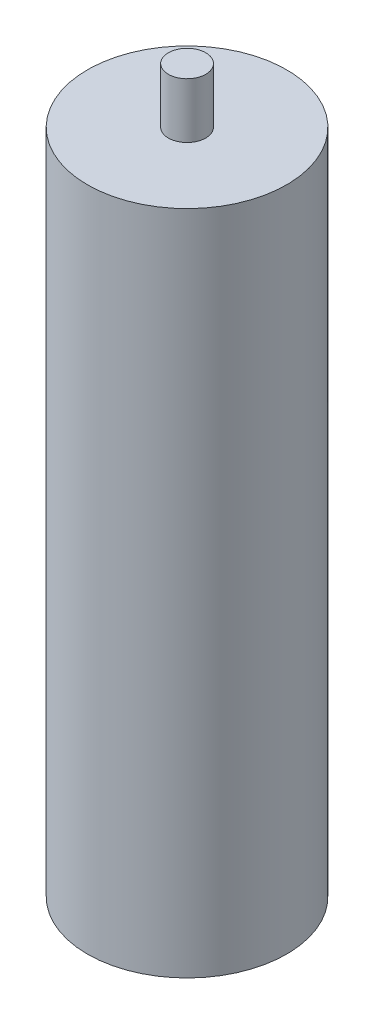
from build123d import *

# Parameters (mm, degrees)
SKETCH1_R            = 6.096
BOSS_EXTRUDE8_DEPTH  = 40.767
SKETCH7_R            = 1.143
BOSS_EXTRUDE10_DEPTH = 3.3782
SKETCH8_R            = 1.143
BOSS_EXTRUDE12_DEPTH = 3.3782


with BuildPart() as part:
    # Sketch1 → Boss-Extrude8 (new body)
    with BuildSketch(Plane(origin=(0, 0, 0), x_dir=(1, 0, 0), z_dir=(0, 1, 0))):
        Circle(SKETCH1_R)
    extrude(amount=BOSS_EXTRUDE8_DEPTH)

    # Sketch7 → Boss-Extrude10 (add)
    with BuildSketch(Plane.XZ):
        Circle(SKETCH7_R)
    extrude(amount=BOSS_EXTRUDE10_DEPTH)

    # Sketch8 → Boss-Extrude12 (add)
    with BuildSketch(Plane(origin=(0, 40.767, 0), x_dir=(1, 0, 0), z_dir=(0, 1, 0))):
        Circle(SKETCH8_R)
    extrude(amount=BOSS_EXTRUDE12_DEPTH)


solid = part.part
